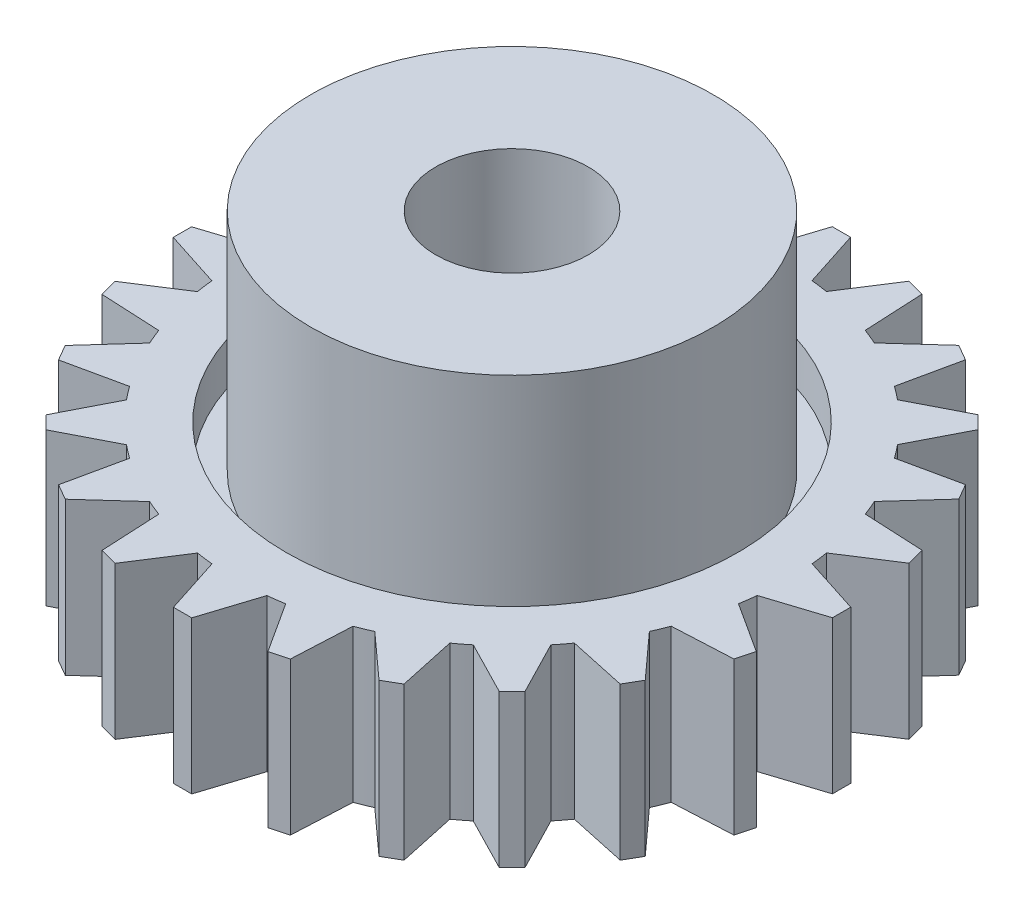
from build123d import *

# Parameters (mm, degrees)
SKETCH1_R           = 11.4046
SKETCH1_R_2         = 8.382
BOSS_EXTRUDE1_DEPTH = 6.35
SKETCH1_3_R         = 8.382
SKETCH1_3_R_2       = 3.175
BOSS_EXTRUDE2_DEPTH = 13.97
SKETCH1_4_R         = 9.398
SKETCH1_4_R_2       = 8.382
CUT_EXTRUDE1_DEPTH  = 1.778
CUT_EXTRUDE3_START  = 4.572
SKETCH1_8_R         = 9.398
SKETCH1_8_R_2       = 8.382
CUT_EXTRUDE3_DEPTH  = 1.778
BOSS_EXTRUDE3_START = -6.35
BOSS_EXTRUDE3_DEPTH = 6.35
CIRPATTERN1_COUNT   = 24


with BuildPart() as part:
    # Sketch1 → Boss-Extrude1 (new body)
    with BuildSketch(Plane(origin=(0, 0, 0), x_dir=(1, 0, 0), z_dir=(0, 1, 0))):
        Circle(SKETCH1_R)
        Circle(SKETCH1_R_2, mode=Mode.SUBTRACT)
    extrude(amount=BOSS_EXTRUDE1_DEPTH)

    # Sketch1_3 → Boss-Extrude2 (add)
    with BuildSketch(Plane(origin=(0, 0, 0), x_dir=(1, 0, 0), z_dir=(0, 1, 0))):
        Circle(SKETCH1_3_R)
        Circle(SKETCH1_3_R_2, mode=Mode.SUBTRACT)
    extrude(amount=BOSS_EXTRUDE2_DEPTH)

    # Sketch1_4 → Cut-Extrude1 (cut)
    with BuildSketch(Plane(origin=(0, 0, 0), x_dir=(1, 0, 0), z_dir=(0, 1, 0))):
        Circle(SKETCH1_4_R)
        Circle(SKETCH1_4_R_2, mode=Mode.SUBTRACT)
    extrude(amount=CUT_EXTRUDE1_DEPTH, mode=Mode.SUBTRACT)

    # Sketch1_8 → Cut-Extrude3 (cut)
    with BuildSketch(Plane(origin=(0, 0, 0), x_dir=(1, 0, 0), z_dir=(0, 1, 0)).offset(CUT_EXTRUDE3_START)):
        Circle(SKETCH1_8_R)
        Circle(SKETCH1_8_R_2, mode=Mode.SUBTRACT)
    extrude(amount=CUT_EXTRUDE3_DEPTH, mode=Mode.SUBTRACT)

    # Sketch2 → Boss-Extrude3 (add)
    with BuildSketch(Plane(origin=(0, 6.35, 0), x_dir=(1, 0, 0), z_dir=(0, 1, 0)).offset(BOSS_EXTRUDE3_START)):
        with BuildLine():
            Line((0.3772543, 13.715999489), (-0.3847457, 13.715999489))
            Line((-0.3847457, 13.715999489), (-1.145852444, 11.34689047))
            ThreePointArc((-1.145852444, 11.34689047), (-0.002866915, 11.40459964), (1.140147484, 11.34746513))
            Line((1.140147484, 11.34746513), (0.3772543, 13.715999489))
        make_face()
    boss_extrude3 = extrude(amount=BOSS_EXTRUDE3_DEPTH)

    # CirPattern1: Boss-Extrude3 ×24 about axis
    cirpattern1_axis = Axis((0, 6.35, 0), (0, -1, 0))
    for i in range(1, CIRPATTERN1_COUNT):
        add(boss_extrude3.rotate(cirpattern1_axis, i * 360 / CIRPATTERN1_COUNT))


solid = part.part
